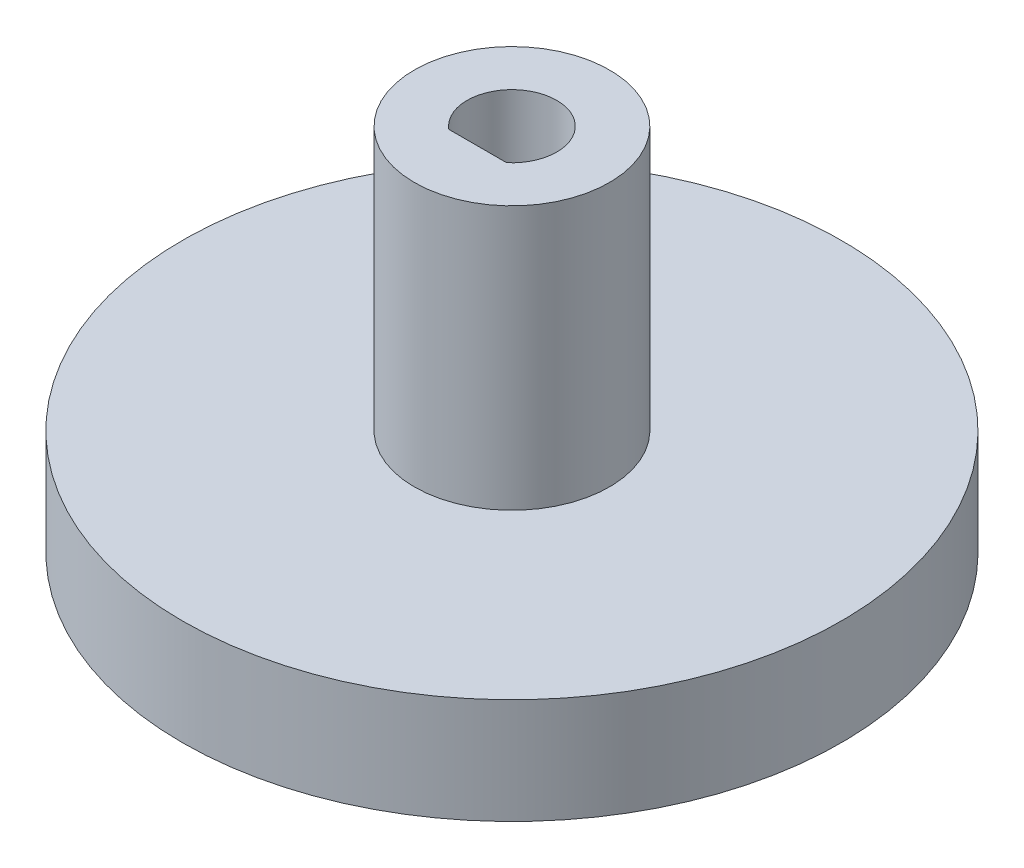
from build123d import *

# Parameters (mm, degrees)
SKETCH1_R           = 12.5
BOSS_EXTRUDE1_DEPTH = 4
SKETCH2_R           = 3.7
BOSS_EXTRUDE2_DEPTH = 10


with BuildPart() as part:
    # Sketch1 → Boss-Extrude1 (new body)
    with BuildSketch(Plane(origin=(0, 0, 0), x_dir=(1, 0, 0), z_dir=(0, 1, 0))):
        Circle(SKETCH1_R)
        with BuildLine():
            Line((1.095445115, -1.3), (-1.095445115, -1.3))
            ThreePointArc((-1.095445115, -1.3), (0, 1.7), (1.095445115, -1.3))
        make_face(mode=Mode.SUBTRACT)
    extrude(amount=BOSS_EXTRUDE1_DEPTH)

    # Sketch2 → Boss-Extrude2 (add)
    with BuildSketch(Plane(origin=(0, 4, 0), x_dir=(1, 0, 0), z_dir=(0, 1, 0))):
        Circle(SKETCH2_R)
        with BuildLine():
            Line((-1.095445115, -1.3), (1.095445115, -1.3))
            ThreePointArc((1.095445115, -1.3), (0, 1.7), (-1.095445115, -1.3))
        make_face(mode=Mode.SUBTRACT)
    extrude(amount=BOSS_EXTRUDE2_DEPTH)


solid = part.part
